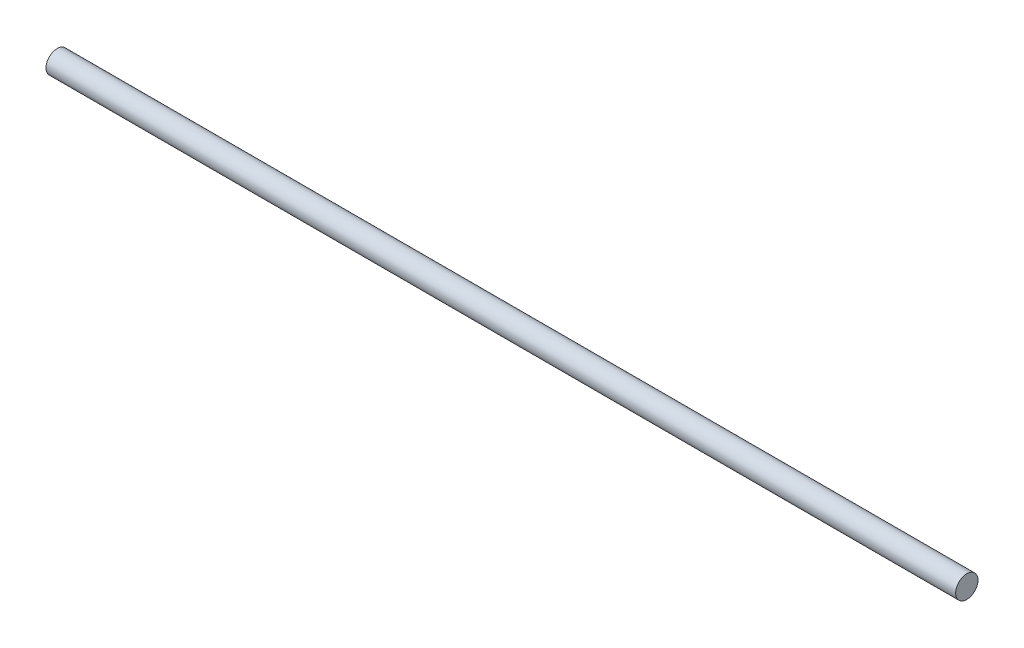
from build123d import *

# Parameters (mm, degrees)
SKETCH1_R                = 0.75
BOSS_EXTRUDE1_DEPTH      = 50
BOSS_EXTRUDE1_DEPTH_BACK = 11


with BuildPart() as part:
    # Sketch1 → Boss-Extrude1 (new body, two sides)
    with BuildSketch(Plane(origin=(0, 0, 0), x_dir=(0, 0, -1), z_dir=(1, 0, 0))) as boss_extrude1_sk:
        Circle(SKETCH1_R)
    extrude(amount=BOSS_EXTRUDE1_DEPTH)
    extrude(boss_extrude1_sk.sketch, amount=-BOSS_EXTRUDE1_DEPTH_BACK)


solid = part.part
